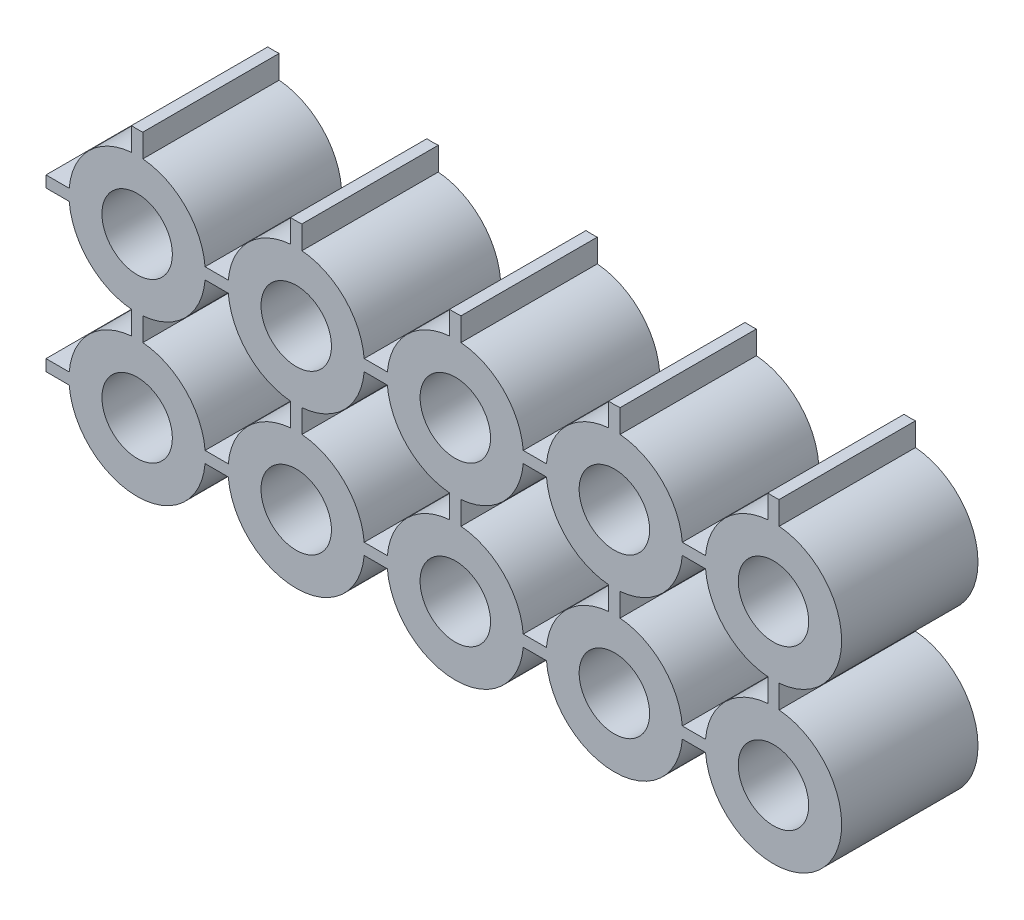
from build123d import *

# Parameters (mm, degrees)
ESQUISSE1_R                     = 1.55
BOSS_EXTRU_2_DEPTH              = 6
R_P_TITION_LIN_AIRE1_COUNT      = 2
R_P_TITION_LIN_AIRE1_PITCH      = 7
R_P_TITION_LIN_AIRE1_COUNT_DIR2 = 5
R_P_TITION_LIN_AIRE1_PITCH_DIR2 = 7


with BuildPart() as part:
    # Esquisse1 → Boss.-Extru.2 (new body)
    with BuildSketch(Plane.XY):
        with BuildLine():
            Line((-0.25, 4.010434814), (-0.25, 2.989565186))
            ThreePointArc((-0.25, 2.989565186), (-2.121320344, 2.121320344), (-2.989565186, 0.25))
            Line((-2.989565186, 0.25), (-4.010434814, 0.25))
            ThreePointArc((-4.010434814, 0.25), (-4, 0), (-4.010434814, -0.25))
            Line((-4.010434814, -0.25), (-2.989565186, -0.25))
            ThreePointArc((-2.989565186, -0.25), (2.121320344, -2.121320344), (0.25, 2.989565186))
            Line((0.25, 2.989565186), (0.25, 4.010434814))
            ThreePointArc((0.25, 4.010434814), (0, 4), (-0.25, 4.010434814))
        make_face()
        Circle(ESQUISSE1_R, mode=Mode.SUBTRACT)
    boss_extru_2 = extrude(amount=BOSS_EXTRU_2_DEPTH)

    # Répétition linéaire1: Boss.-Extru.2 2 × 5
    with Locations(*[(j * R_P_TITION_LIN_AIRE1_PITCH_DIR2, -i * R_P_TITION_LIN_AIRE1_PITCH, 0) for i in range(R_P_TITION_LIN_AIRE1_COUNT) for j in range(R_P_TITION_LIN_AIRE1_COUNT_DIR2) if (i, j) != (0, 0)]):
        add(boss_extru_2)


solid = part.part
